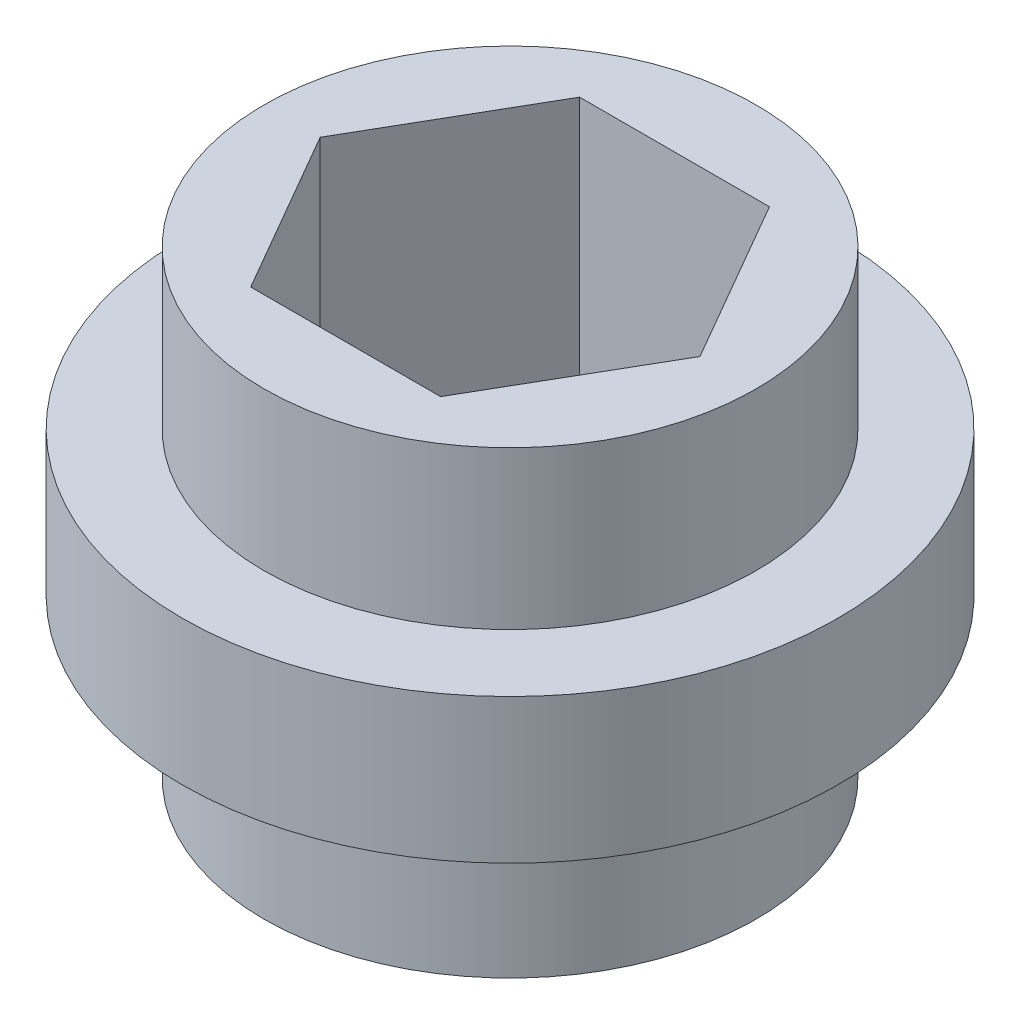
from build123d import *

# Parameters (mm, degrees)
SKETCH1_R           = 7.5
BOSS_EXTRUDE1_DEPTH = 7
SKETCH1_3_R         = 10
BOSS_EXTRUDE2_DEPTH = 2.2


with BuildPart() as part:
    # Sketch1 → Boss-Extrude1 (new, symmetric)
    with BuildSketch(Plane(origin=(0, 0, 0), x_dir=(1, 0, 0), z_dir=(0, 1, 0))):
        Circle(SKETCH1_R)
        Polygon((2.893968224, -5.0125), (-2.893968224, -5.0125), (-5.787936449, 0), (-2.893968224, 5.0125), (2.893968224, 5.0125), (5.787936449, 0), align=None, mode=Mode.SUBTRACT)
    extrude(amount=BOSS_EXTRUDE1_DEPTH, both=True)

    # Sketch1_3 → Boss-Extrude2 (add, symmetric)
    with BuildSketch(Plane(origin=(0, 0, 0), x_dir=(1, 0, 0), z_dir=(0, 1, 0))):
        Circle(SKETCH1_3_R)
        Polygon((2.893968224, -5.0125), (-2.893968224, -5.0125), (-5.787936449, 0), (-2.893968224, 5.0125), (2.893968224, 5.0125), (5.787936449, 0), align=None, mode=Mode.SUBTRACT)
    extrude(amount=BOSS_EXTRUDE2_DEPTH, both=True)


solid = part.part
